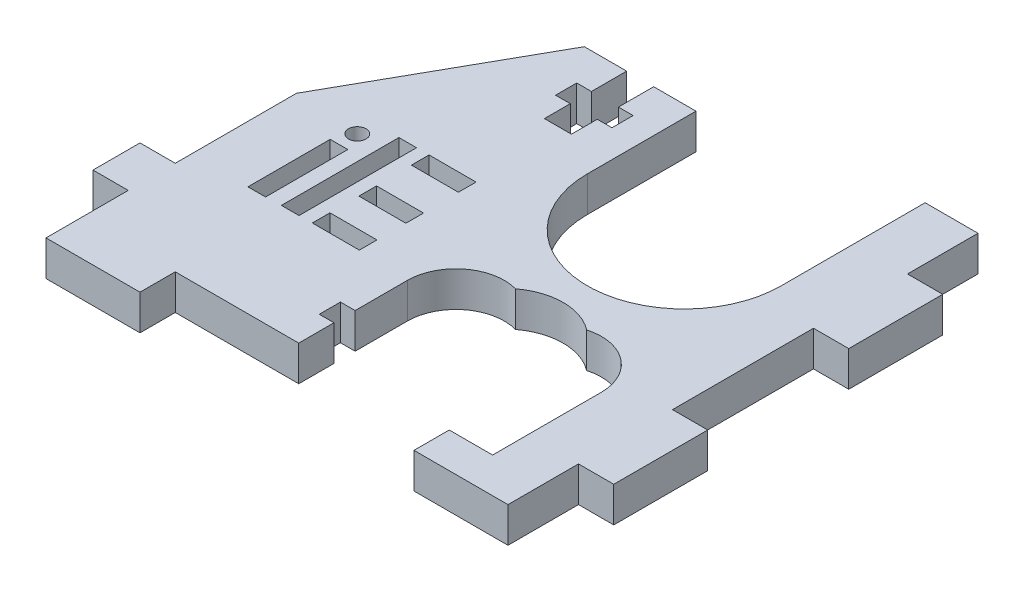
from build123d import *

# Parameters (mm, degrees)
SKETCH1_W           = 30.5
SKETCH1_H           = 34
BOSS_EXTRUDE1_DEPTH = 1.5
BOSS_EXTRUDE2_DEPTH = 3
SKETCH3_W           = 3
SKETCH3_H           = 8
SKETCH3_W_2         = 8
SKETCH3_H_2         = 3
BOSS_EXTRUDE3_DEPTH = 3
CUT_EXTRUDE1_DEPTH  = 4.0000001
CUT_EXTRUDE2_DEPTH  = 4.0000001
SKETCH6_W           = 8
SKETCH6_H           = 3
CUT_EXTRUDE3_DEPTH  = 4.0000001
CUT_EXTRUDE4_DEPTH  = 4.0000001
CUT_EXTRUDE6_DEPTH  = 4.0000001
SKETCH14_W          = 16.5
SKETCH14_H          = 9.25
CUT_EXTRUDE8_DEPTH  = 10
CUT_EXTRUDE10_DEPTH = 10
SKETCH18_R          = 5
CUT_EXTRUDE11_DEPTH = 10
SKETCH19_R          = 0.75
SKETCH19_W          = 4
SKETCH19_H          = 1.5
SKETCH19_W_2        = 1.5
SKETCH19_H_2        = 10
SKETCH19_H_3        = 7
CUT_EXTRUDE12_DEPTH = 10
SKETCH9_W           = 3
SKETCH9_H           = 4
BOSS_EXTRUDE4_DEPTH = 3


with BuildPart() as part:
    # Sketch1 → Boss-Extrude1 (new body, symmetric)
    with BuildSketch(Plane(origin=(0, 0, 0), x_dir=(1, 0, 0), z_dir=(0, 1, 0))):
        Rectangle(SKETCH1_W, SKETCH1_H)
    extrude(amount=BOSS_EXTRUDE1_DEPTH, both=True)

    # Sketch2 → Boss-Extrude2 (add)
    with BuildSketch(Plane(origin=(0, 1.5, 0), x_dir=(1, 0, 0), z_dir=(0, 1, 0))):
        with BuildLine():
            Line((-15.25, 17), (-24.07, 1.308996208))
            add(Edge.make_bspline(
                [(-24.07, 1.308996208), (-25.612124036, -1.43448158), (-30.226003395, -1.5229993), (-46.69780929, -11.088418218), (-55.382760657, -10.307171359), (-55.382760657, -17)],
                knots=[0, 0, 0, 0, 0.221130071, 0.603599568, 1, 1, 1, 1], degree=3))
            Line((-55.382760657, -17), (-15.25, -17))
            Line((-15.25, -17), (-15.25, 17))
        make_face()
    extrude(amount=-BOSS_EXTRUDE2_DEPTH)

    # Sketch3 → Boss-Extrude3 (add)
    with BuildSketch(Plane(origin=(0, 1.5, 0), x_dir=(1, 0, 0), z_dir=(0, 1, 0))):
        with Locations((16.75, 10)):
            Rectangle(SKETCH3_W, SKETCH3_H)
        with Locations((16.75, -10)):
            Rectangle(SKETCH3_W, SKETCH3_H)
        with Locations((-11.25, 18.5)):
            Rectangle(SKETCH3_W_2, SKETCH3_H_2)
        with Locations((11.25, 18.5)):
            Rectangle(SKETCH3_W_2, SKETCH3_H_2)
        with Locations((-51.382760657, -18.5)):
            Rectangle(SKETCH3_W_2, SKETCH3_H_2)
        with Locations((11.25, -18.5)):
            Rectangle(SKETCH3_W_2, SKETCH3_H_2)
        with Locations((-20.066380328, -18.5)):
            Rectangle(SKETCH3_W_2, SKETCH3_H_2)
    extrude(amount=-BOSS_EXTRUDE3_DEPTH)

    # Sketch4 → Cut-Extrude1 (cut, through all)
    with BuildSketch(Plane(origin=(0, 1.5, 0), x_dir=(1, 0, 0), z_dir=(0, 1, 0))):
        Polygon((-2.008190164, -14), (-2.008190164, -12.2), (-3.258190164, -12.2), (-3.258190164, -10), (-5.558190164, -10), (-5.558190164, -12.2), (-6.808190164, -12.2), (-6.808190164, -14), (-5.558190164, -14), (-5.558190164, -17), (-3.258190164, -17), (-3.258190164, -14), align=None)
        Polygon((-33.324570493, -14), (-33.324570493, -12.2), (-34.574570493, -12.2), (-34.574570493, -10), (-36.874570493, -10), (-36.874570493, -12.2), (-38.124570493, -12.2), (-38.124570493, -14), (-36.874570493, -14), (-36.874570493, -17), (-34.574570493, -17), (-34.574570493, -14), align=None)
    extrude(amount=-CUT_EXTRUDE1_DEPTH, mode=Mode.SUBTRACT)

    # Sketch5 → Cut-Extrude2 (cut, through all)
    with BuildSketch(Plane(origin=(0, 1.5, 0), x_dir=(1, 0, 0), z_dir=(0, 1, 0))):
        with BuildLine():
            Line((10.75, 20), (10.75, 7.75))
            ThreePointArc((10.75, 7.75), (2.5, -0.5), (-5.75, 7.75))
            Line((-5.75, 7.75), (-5.75, 20))
            Line((-5.75, 20), (10.75, 20))
        make_face()
    extrude(amount=-CUT_EXTRUDE2_DEPTH, mode=Mode.SUBTRACT)

    # Sketch6 → Cut-Extrude3 (cut, through all)
    with BuildSketch(Plane(origin=(0, 1.5, 0), x_dir=(1, 0, 0), z_dir=(0, 1, 0))):
        with Locations((-11.25, 18.5)):
            Rectangle(SKETCH6_W, SKETCH6_H)
    extrude(amount=-CUT_EXTRUDE3_DEPTH, mode=Mode.SUBTRACT)

    # Sketch7 → Cut-Extrude4 (cut, through all)
    with BuildSketch(Plane(origin=(0, 1.5, 0), x_dir=(1, 0, 0), z_dir=(0, 1, 0))):
        Polygon((-11.65, 17), (-9.35, 17), (-9.35, 14), (-8.1, 14), (-8.1, 12.2), (-9.35, 12.2), (-9.35, 10), (-11.65, 10), (-11.65, 12.2), (-12.9, 12.2), (-12.9, 14), (-11.65, 14), align=None)
    extrude(amount=-CUT_EXTRUDE4_DEPTH, mode=Mode.SUBTRACT)

    # Sketch8 → Cut-Extrude6 (cut, through all)
    with BuildSketch(Plane(origin=(0, 1.5, 0), x_dir=(1, 0, 0), z_dir=(0, 1, 0))):
        with BuildLine():
            Line((-24.066380328, -17), (-24.066380328, 1.315435696))
            Line((-24.066380328, 1.315435696), (-24.07, 1.308996208))
            add(Edge.make_bspline(
                [(-24.07, 1.308996208), (-25.612124036, -1.43448158), (-30.226003395, -1.5229993), (-46.69780929, -11.088418218), (-55.382760657, -10.307171359), (-55.382760657, -17)],
                knots=[0, 0, 0, 0, 0.221130071, 0.603599568, 1, 1, 1, 1], degree=3))
            Line((-55.382760657, -17), (-55.382760657, -20))
            Line((-55.382760657, -20), (-47.382760657, -20))
            Line((-47.382760657, -20), (-47.382760657, -17))
            Line((-47.382760657, -17), (-36.874570493, -17))
            Line((-36.874570493, -17), (-36.874570493, -14))
            Line((-36.874570493, -14), (-38.124570493, -14))
            Line((-38.124570493, -14), (-38.124570493, -12.2))
            Line((-38.124570493, -12.2), (-36.874570493, -12.2))
            Line((-36.874570493, -12.2), (-36.874570493, -10))
            Line((-36.874570493, -10), (-34.574570493, -10))
            Line((-34.574570493, -10), (-34.574570493, -12.2))
            Line((-34.574570493, -12.2), (-33.324570493, -12.2))
            Line((-33.324570493, -12.2), (-33.324570493, -14))
            Line((-33.324570493, -14), (-34.574570493, -14))
            Line((-34.574570493, -14), (-34.574570493, -17))
            Line((-34.574570493, -17), (-24.066380328, -17))
        make_face()
    extrude(amount=-CUT_EXTRUDE6_DEPTH, mode=Mode.SUBTRACT)

    # Sketch14 → Cut-Extrude8 (cut)
    with BuildSketch(Plane(origin=(0, 1.5, 0), x_dir=(1, 0, 0), z_dir=(0, 1, 0))):
        with Locations((2.691809836, -12.375)):
            Rectangle(SKETCH14_W, SKETCH14_H)
    extrude(amount=-CUT_EXTRUDE8_DEPTH, mode=Mode.SUBTRACT)

    # Sketch16 → Cut-Extrude10 (cut)
    with BuildSketch(Plane(origin=(0, 1.5, 0), x_dir=(1, 0, 0), z_dir=(0, 1, 0))):
        with BuildLine():
            Line((-5.558190164, -7.75), (2.691809836, -7.75))
            ThreePointArc((2.691809836, -7.75), (-1.433190164, -3.625), (-5.558190164, -7.75))
        make_face()
        with BuildLine():
            ThreePointArc((-5.558190164, -7.75), (-1.433190164, -11.875), (2.691809836, -7.75))
            Line((2.691809836, -7.75), (-5.558190164, -7.75))
        make_face()
        with BuildLine():
            Line((10.941809836, -7.75), (2.691809836, -7.75))
            ThreePointArc((2.691809836, -7.75), (6.816809836, -11.875), (10.941809836, -7.75))
        make_face()
        with BuildLine():
            ThreePointArc((10.941809836, -7.75), (6.816809836, -3.625), (2.691809836, -7.75))
            Line((2.691809836, -7.75), (10.941809836, -7.75))
        make_face()
    extrude(amount=-CUT_EXTRUDE10_DEPTH, mode=Mode.SUBTRACT)

    # Sketch18 → Cut-Extrude11 (cut)
    with BuildSketch(Plane(origin=(0, 1.5, 0), x_dir=(1, 0, 0), z_dir=(0, 1, 0))):
        with Locations((2.691809836, -7.75)):
            Circle(SKETCH18_R)
    extrude(amount=-CUT_EXTRUDE11_DEPTH, mode=Mode.SUBTRACT)

    # Sketch19 → Cut-Extrude12 (cut)
    with BuildSketch(Plane(origin=(0, 1.5, 0), x_dir=(1, 0, 0), z_dir=(0, 1, 0))):
        with Locations((-18.487833601, 0.912762829)):
            Circle(SKETCH19_R)
        with Locations((-11.831571961, -2.855782843)):
            Rectangle(SKETCH19_W, SKETCH19_H)
        with Locations((-15.694739931, -2.587237171)):
            Rectangle(SKETCH19_W_2, SKETCH19_H_2)
        with Locations((-11.881312648, 1.662762829)):
            Rectangle(SKETCH19_W, SKETCH19_H)
        with Locations((-11.831571961, -6.818375842)):
            Rectangle(SKETCH19_W, SKETCH19_H)
        with Locations((-18.487833601, -4.143833383)):
            Rectangle(SKETCH19_W_2, SKETCH19_H_3)
    extrude(amount=-CUT_EXTRUDE12_DEPTH, mode=Mode.SUBTRACT)

    # Sketch9 → Boss-Extrude4 (add)
    with BuildSketch(Plane(origin=(0, 1.5, 0), x_dir=(1, 0, 0), z_dir=(0, 1, 0))):
        with Locations((-25.566380328, -11)):
            Rectangle(SKETCH9_W, SKETCH9_H)
    extrude(amount=-BOSS_EXTRUDE4_DEPTH)


solid = part.part
